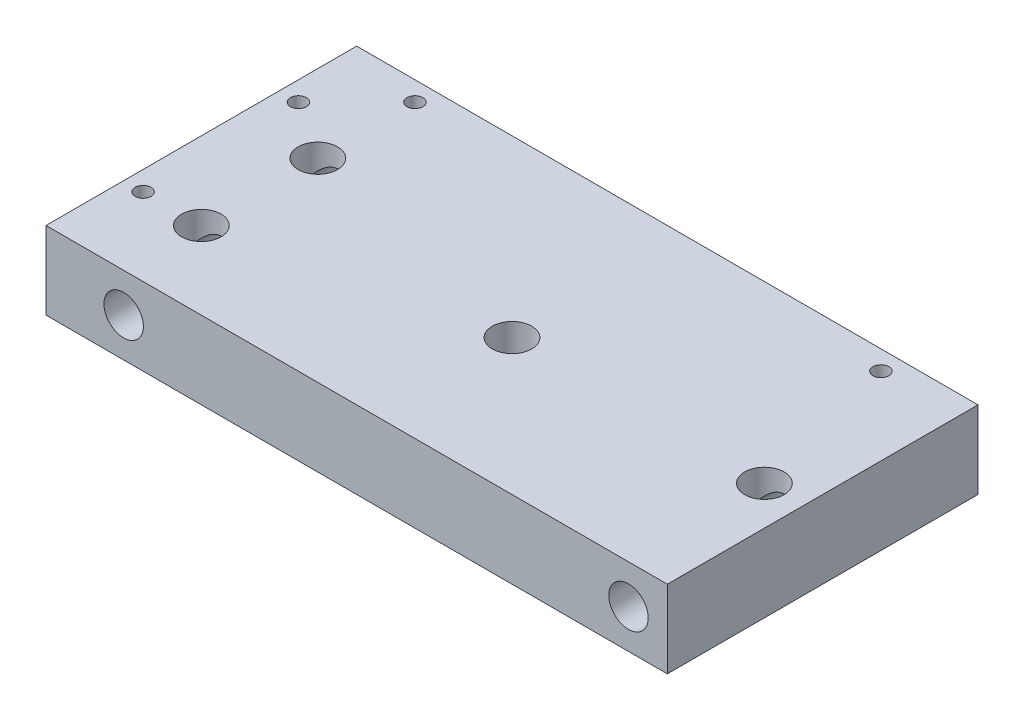
from build123d import *

# Parameters (mm, degrees)
SKETCH1_W                   = 200
SKETCH1_H                   = 100
BOSS_EXTRUDE1_DEPTH         = 25
SKETCH2_R                   = 6.35
CUT_EXTRUDE1_DEPTH          = 87.5
SKETCH3_R                   = 6.35
CUT_EXTRUDE2_DEPTH          = 19
CUT_EXTRUDE3_REACH          = 27
SKETCH4_R                   = 6.35
CUT_EXTRUDE4_DEPTH          = 6.35
F_1_4_20_TAPPED_HOLE1_D     = 5.1054
F_1_4_20_TAPPED_HOLE1_DEPTH = 25


with BuildPart() as part:
    # Sketch1 → Boss-Extrude1 (new body)
    with BuildSketch(Plane(origin=(0, 0, 0), x_dir=(1, 0, 0), z_dir=(0, 1, 0))):
        Rectangle(SKETCH1_W, SKETCH1_H)
    extrude(amount=BOSS_EXTRUDE1_DEPTH)

    # Sketch2 → Cut-Extrude1 (cut)
    with BuildSketch(Plane.XY.offset(50)):
        with Locations((-75, 12.5)):
            Circle(SKETCH2_R)
        with Locations((87.500000108, 12.5)):
            Circle(SKETCH2_R)
    extrude(amount=-CUT_EXTRUDE1_DEPTH, mode=Mode.SUBTRACT)

    # Sketch3 → Cut-Extrude2 (cut)
    with BuildSketch(Plane(origin=(0, 25, 0), x_dir=(1, 0, 0), z_dir=(0, 1, 0))):
        with Locations((-75, 12.5)):
            Circle(SKETCH3_R)
        with Locations((-75, -25)):
            Circle(SKETCH3_R)
        with Locations((87.500000108, -6.25)):
            Circle(SKETCH3_R)
    extrude(amount=-CUT_EXTRUDE2_DEPTH, mode=Mode.SUBTRACT)

    # Sketch4 → Cut-Extrude3 (cut, up to next)
    with BuildSketch(Plane(origin=(0, 25, 0), x_dir=(1, 0, 0), z_dir=(0, 1, 0)), mode=Mode.PRIVATE) as cut_extrude3_sk1:
        with Locations((6.25, -6.25)):
            Circle(SKETCH4_R)
    cut_extrude3_tool1 = extrude(cut_extrude3_sk1.sketch, amount=-CUT_EXTRUDE3_REACH, mode=Mode.PRIVATE) & part.part
    add(cut_extrude3_tool1.solids().sort_by_distance((6.25, 25, 6.25))[0], mode=Mode.SUBTRACT)

    # Sketch5 → Cut-Extrude4 (cut)
    with BuildSketch(Plane(origin=(0, 0, 0), x_dir=(-1, 0, 0), z_dir=(0, -1, 0))):
        with BuildLine():
            Line((-9.425, 7.143897512), (-9.425, -0.750738686))
            ThreePointArc((-9.425, -0.750738686), (-6.25, 0.1), (-3.075, -0.750738686))
            Line((-3.075, -0.750738686), (-3.075, 7.143897512))
            ThreePointArc((-3.075, 7.143897512), (-6.25, 10.318897512), (-9.425, 7.143897512))
        make_face()
        with BuildLine():
            Line((-9.425, -11.749261314), (-9.425, -18.256102488))
            ThreePointArc((-9.425, -18.256102488), (-6.25, -21.431102488), (-3.075, -18.256102488))
            Line((-3.075, -18.256102488), (-3.075, -11.749261314))
            ThreePointArc((-3.075, -11.749261314), (-6.25, -12.6), (-9.425, -11.749261314))
        make_face()
    extrude(amount=-CUT_EXTRUDE4_DEPTH, mode=Mode.SUBTRACT)

    # 1/4-20 Tapped Hole1
    with Locations(Plane(origin=(-75, 25, -43.75), x_dir=(0, 0, 1), z_dir=(0, 1, 0))):
        with Locations((0, 0), (0, 150), (18.75, -18.75), (68.75, -18.75)):
            Hole(F_1_4_20_TAPPED_HOLE1_D / 2, depth=F_1_4_20_TAPPED_HOLE1_DEPTH)


solid = part.part
